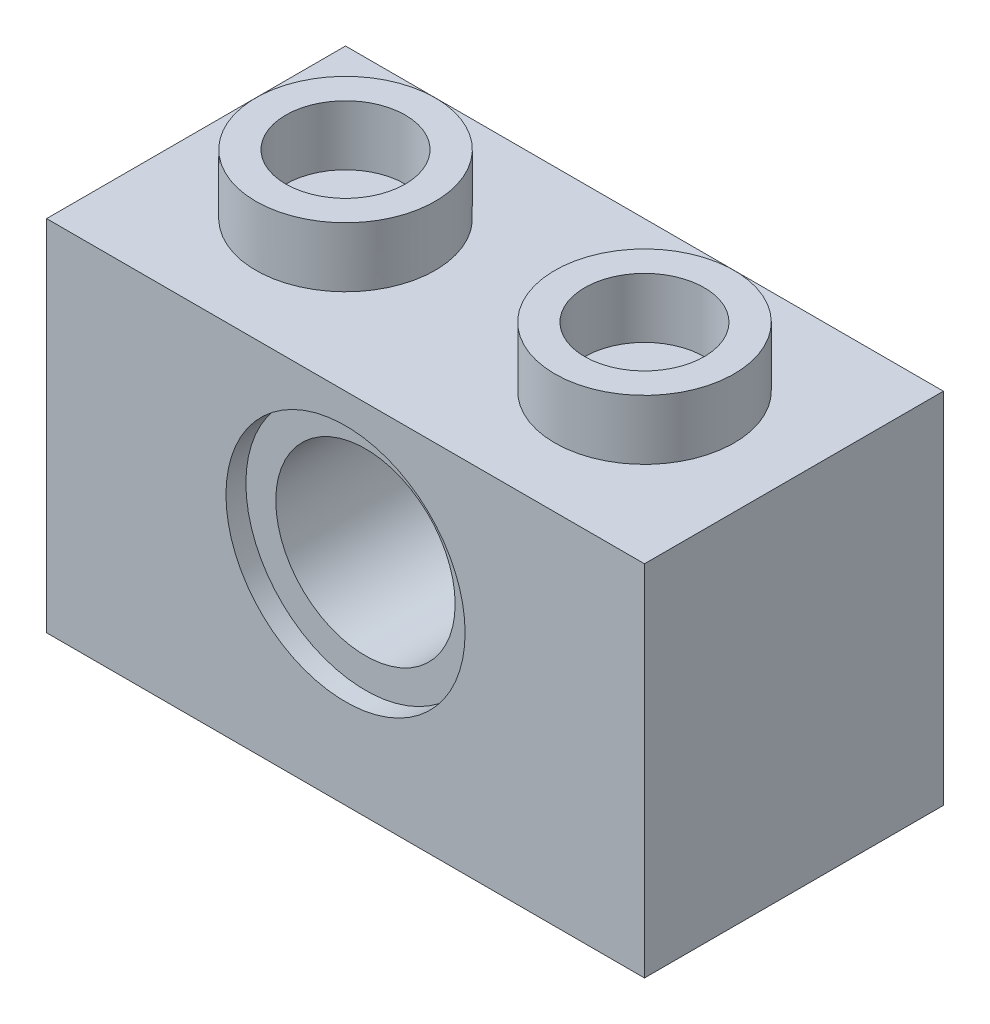
from build123d import *

# Parameters (mm, degrees)
SKETCH1_W           = 10
SKETCH1_H           = 5
SKETCH1_W_2         = 8
SKETCH1_H_2         = 3
BOSS_EXTRUDE1_DEPTH = 6
BOSS_EXTRUDE2_REACH = 11
SKETCH2_W           = 3
SKETCH2_H           = 1
SKETCH4_R           = 1.5
SKETCH4_R_2         = 1
BOSS_EXTRUDE3_DEPTH = 1
BOSS_EXTRUDE4_DEPTH = 5
BOSS_EXTRUDE5_DEPTH = 5
CUT_EXTRUDE2_DEPTH  = 5
CUT_EXTRUDE3_DEPTH  = 0.333333333
SKETCH8_R           = 2
CUT_EXTRUDE4_DEPTH  = 0.333333333


with BuildPart() as part:
    # Sketch1 → Boss-Extrude1 (new body)
    with BuildSketch(Plane(origin=(0, 0, 0), x_dir=(1, 0, 0), z_dir=(0, 1, 0))):
        with Locations((5, 2.5)):
            Rectangle(SKETCH1_W, SKETCH1_H)
        with Locations((5, 2.5)):
            Rectangle(SKETCH1_W_2, SKETCH1_H_2, mode=Mode.SUBTRACT)
    extrude(amount=BOSS_EXTRUDE1_DEPTH)

    # Sketch2 → Boss-Extrude2 (add, up to next)
    with BuildSketch(Plane(origin=(1, 0, 0), x_dir=(0, 0, -1), z_dir=(1, 0, 0)), mode=Mode.PRIVATE) as boss_extrude2_sk1:
        with Locations((2.5, 5.5)):
            Rectangle(SKETCH2_W, SKETCH2_H)
    boss_extrude2_tool1 = extrude(boss_extrude2_sk1.sketch, amount=BOSS_EXTRUDE2_REACH, mode=Mode.PRIVATE) - part.part
    add(boss_extrude2_tool1.solids().sort_by_distance((1, 5.5, -2.5))[0])

    # Sketch4 → Boss-Extrude3 (add)
    with BuildSketch(Plane(origin=(0, 6, 0), x_dir=(1, 0, 0), z_dir=(0, 1, 0))):
        with Locations((2.5, 2.5)):
            Circle(SKETCH4_R)
        with Locations((2.5, 2.5)):
            Circle(SKETCH4_R_2, mode=Mode.SUBTRACT)
        with Locations((7.5, 2.5)):
            Circle(SKETCH4_R)
        with Locations((7.5, 2.5)):
            Circle(SKETCH4_R_2, mode=Mode.SUBTRACT)
    extrude(amount=BOSS_EXTRUDE3_DEPTH)

    # Sketch6 → Boss-Extrude4 (add)
    with BuildSketch(Plane(origin=(0, 5, 0), x_dir=(-1, 0, 0), z_dir=(0, -1, 0))):
        with BuildLine():
            ThreePointArc((-6, 2.5), (-5, 1.5), (-4, 2.5))
            Line((-4, 2.5), (-6, 2.5))
        make_face()
        with BuildLine():
            Line((-6, 2.5), (-4, 2.5))
            ThreePointArc((-4, 2.5), (-5, 3.5), (-6, 2.5))
        make_face()
    extrude(amount=BOSS_EXTRUDE4_DEPTH)

    # Sketch7 → Boss-Extrude5 (add)
    with BuildSketch(Plane(origin=(0, 0, -5), x_dir=(-1, 0, 0), z_dir=(0, 0, -1))):
        with BuildLine():
            ThreePointArc((-5, 5.5), (-7, 3.5), (-5, 1.5))
            Line((-5, 1.5), (-5, 2))
            ThreePointArc((-5, 2), (-6.5, 3.5), (-5, 5))
            Line((-5, 5), (-5, 5.5))
        make_face()
        with BuildLine():
            Line((-5, 2), (-5, 1.5))
            ThreePointArc((-5, 1.5), (-3.585786438, 2.085786438), (-3, 3.5))
            ThreePointArc((-3, 3.5), (-3.585786438, 4.914213562), (-5, 5.5))
            Line((-5, 5.5), (-5, 5))
            ThreePointArc((-5, 5), (-3.939339828, 4.560660172), (-3.5, 3.5))
            ThreePointArc((-3.5, 3.5), (-3.939339828, 2.439339828), (-5, 2))
        make_face()
        with BuildLine():
            ThreePointArc((-5, 5), (-6.5, 3.5), (-5, 2))
            Line((-5, 2), (-5, 5))
        make_face()
        with BuildLine():
            Line((-5, 5), (-5, 2))
            ThreePointArc((-5, 2), (-3.939339828, 2.439339828), (-3.5, 3.5))
            ThreePointArc((-3.5, 3.5), (-3.939339828, 4.560660172), (-5, 5))
        make_face()
    extrude(amount=-BOSS_EXTRUDE5_DEPTH)

    # Sketch7_3 → Cut-Extrude2 (cut)
    with BuildSketch(Plane(origin=(0, 0, -5), x_dir=(-1, 0, 0), z_dir=(0, 0, -1))):
        with BuildLine():
            ThreePointArc((-5, 5), (-6.5, 3.5), (-5, 2))
            Line((-5, 2), (-5, 5))
        make_face()
        with BuildLine():
            Line((-5, 5), (-5, 2))
            ThreePointArc((-5, 2), (-3.939339828, 2.439339828), (-3.5, 3.5))
            ThreePointArc((-3.5, 3.5), (-3.939339828, 4.560660172), (-5, 5))
        make_face()
    extrude(amount=-CUT_EXTRUDE2_DEPTH, mode=Mode.SUBTRACT)

    # Sketch7_4 → Cut-Extrude3 (cut)
    with BuildSketch(Plane(origin=(0, 0, -5), x_dir=(-1, 0, 0), z_dir=(0, 0, -1))):
        with BuildLine():
            ThreePointArc((-5, 5.5), (-7, 3.5), (-5, 1.5))
            Line((-5, 1.5), (-5, 2))
            ThreePointArc((-5, 2), (-6.5, 3.5), (-5, 5))
            Line((-5, 5), (-5, 5.5))
        make_face()
        with BuildLine():
            Line((-5, 2), (-5, 1.5))
            ThreePointArc((-5, 1.5), (-3.585786438, 2.085786438), (-3, 3.5))
            ThreePointArc((-3, 3.5), (-3.585786438, 4.914213562), (-5, 5.5))
            Line((-5, 5.5), (-5, 5))
            ThreePointArc((-5, 5), (-3.939339828, 4.560660172), (-3.5, 3.5))
            ThreePointArc((-3.5, 3.5), (-3.939339828, 2.439339828), (-5, 2))
        make_face()
    extrude(amount=-CUT_EXTRUDE3_DEPTH, mode=Mode.SUBTRACT)

    # Sketch8 → Cut-Extrude4 (cut)
    with BuildSketch(Plane.XY):
        with Locations((5, 3.5)):
            Circle(SKETCH8_R)
    extrude(amount=-CUT_EXTRUDE4_DEPTH, mode=Mode.SUBTRACT)


solid = part.part
